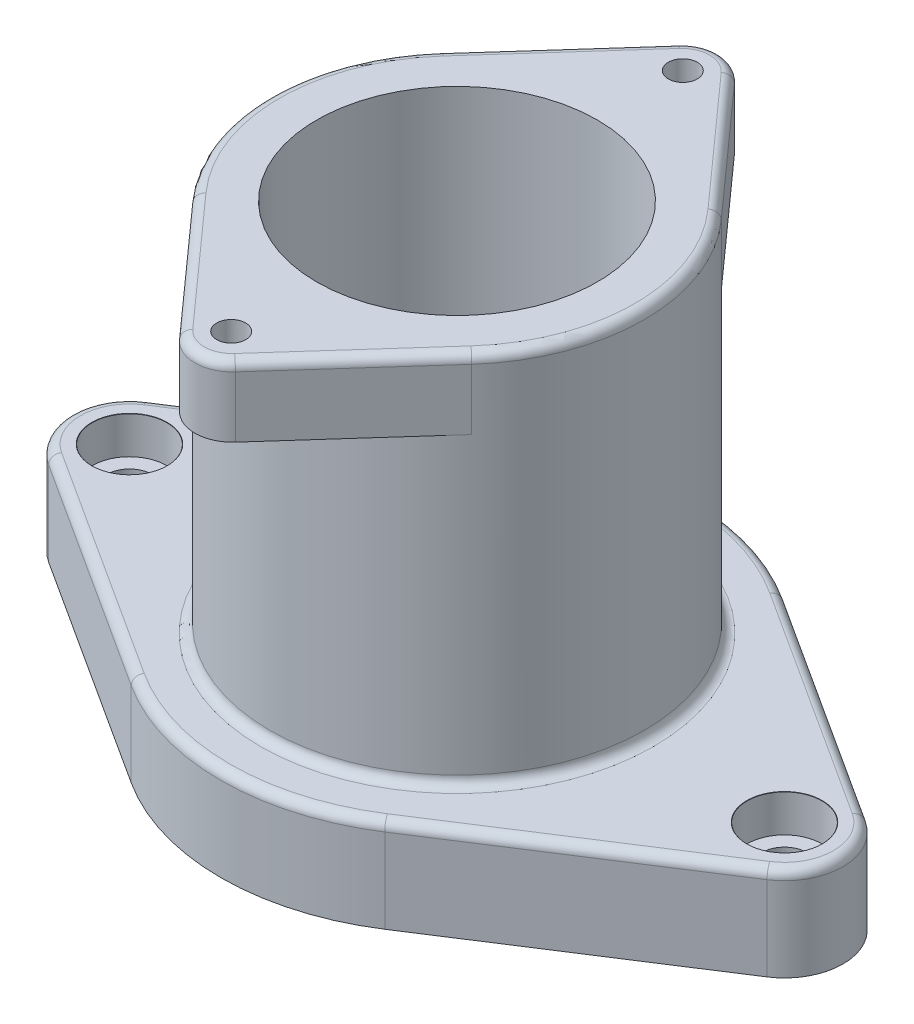
from build123d import *

# Parameters (mm, degrees)
SKETCH1_R                     = 6.25
SKETCH1_R_2                   = 20
SKETCH1_R_3                   = 15
SKETCH1_R_4                   = 1.55
BOSS_EXTRUDE1_DEPTH           = 10
SKETCH1_3_R                   = 20
SKETCH1_3_R_2                 = 15
BOSS_EXTRUDE2_DEPTH           = 40
BOSS_EXTRUDE3_START           = 40
SKETCH1_4_R                   = 1.55
BOSS_EXTRUDE3_DEPTH           = 7.5
CBORE_FOR_M4_SHCS1_AT_2_COUNT = 2
CBORE_FOR_M4_SHCS1_AT_2_PITCH = 70
FILLET1_R                     = 25
FILLET3_R                     = 4
FILLET2_R                     = 1


with BuildPart() as part:
    # Sketch1 → Boss-Extrude1 (new body)
    with BuildSketch(Plane(origin=(0, 0, 0), x_dir=(1, 0, 0), z_dir=(0, 1, 0))):
        with Locations((-35, 0)):
            Circle(SKETCH1_R)
        with BuildLine():
            Line((0, 30), (-38.386505715, 5.253006667))
            ThreePointArc((-38.386505715, 5.253006667), (-32.008609079, 5.487629758), (-28.75, 0))
            ThreePointArc((-28.75, 0), (-32.008609079, -5.487629758), (-38.386505715, -5.253006667))
            Line((-38.386505715, -5.253006667), (0, -30))
            Line((0, -30), (-14.90711985, -13.333333333))
            ThreePointArc((-14.90711985, -13.333333333), (-20, 0), (-14.90711985, 13.333333333))
            Line((-14.90711985, 13.333333333), (0, 30))
        make_face()
        Circle(SKETCH1_R_2)
        Circle(SKETCH1_R_3, mode=Mode.SUBTRACT)
        with BuildLine():
            Line((14.90711985, 13.333333333), (0, 30))
            Line((0, 30), (-14.90711985, 13.333333333))
            ThreePointArc((-14.90711985, 13.333333333), (0, 20), (14.90711985, 13.333333333))
        make_face()
        with Locations((0, 24.13)):
            Circle(SKETCH1_R_4, mode=Mode.SUBTRACT)
        with Locations((0, 24.13)):
            Circle(SKETCH1_R_4)
        with BuildLine():
            Line((38.386505715, 5.253006667), (0, 30))
            Line((0, 30), (14.90711985, 13.333333333))
            ThreePointArc((14.90711985, 13.333333333), (18.683447179, 7.136441795), (20, 0))
            ThreePointArc((20, 0), (18.683447179, -7.136441795), (14.90711985, -13.333333333))
            Line((14.90711985, -13.333333333), (0, -30))
            Line((0, -30), (38.386505715, -5.253006667))
            ThreePointArc((38.386505715, -5.253006667), (28.75, 0), (38.386505715, 5.253006667))
        make_face()
        with BuildLine():
            Line((-14.90711985, -13.333333333), (0, -30))
            Line((0, -30), (14.90711985, -13.333333333))
            ThreePointArc((14.90711985, -13.333333333), (0, -20), (-14.90711985, -13.333333333))
        make_face()
        with Locations((0, -24.13)):
            Circle(SKETCH1_R_4, mode=Mode.SUBTRACT)
        with Locations((0, -24.13)):
            Circle(SKETCH1_R_4)
        with Locations((35, 0)):
            Circle(SKETCH1_R)
    extrude(amount=-BOSS_EXTRUDE1_DEPTH)

    # Sketch1_3 → Boss-Extrude2 (add)
    with BuildSketch(Plane(origin=(0, 0, 0), x_dir=(1, 0, 0), z_dir=(0, 1, 0))):
        Circle(SKETCH1_3_R)
        Circle(SKETCH1_3_R_2, mode=Mode.SUBTRACT)
    extrude(amount=BOSS_EXTRUDE2_DEPTH)

    # Sketch1_4 → Boss-Extrude3 (add)
    with BuildSketch(Plane(origin=(0, 0, 0), x_dir=(1, 0, 0), z_dir=(0, 1, 0)).offset(BOSS_EXTRUDE3_START)):
        with BuildLine():
            Line((14.90711985, 13.333333333), (0, 30))
            Line((0, 30), (-14.90711985, 13.333333333))
            ThreePointArc((-14.90711985, 13.333333333), (0, 20), (14.90711985, 13.333333333))
        make_face()
        with Locations((0, 24.13)):
            Circle(SKETCH1_4_R, mode=Mode.SUBTRACT)
        with BuildLine():
            Line((-14.90711985, -13.333333333), (0, -30))
            Line((0, -30), (14.90711985, -13.333333333))
            ThreePointArc((14.90711985, -13.333333333), (0, -20), (-14.90711985, -13.333333333))
        make_face()
        with Locations((0, -24.13)):
            Circle(SKETCH1_4_R, mode=Mode.SUBTRACT)
    extrude(amount=-BOSS_EXTRUDE3_DEPTH)

    # Sketch3 → CBORE for M4 SHCS1 (revolve, cut)
    with BuildSketch(Plane(origin=(-35, 0, 0), x_dir=(0, 0, 1), z_dir=(1, 0, 0))):
        Polygon((0, 0), (0, 11.442065486), (2.4, 10), (2.4, 4), (4, 4), (4, 0.025), (4.025, 0), align=None)
    cbore_for_m4_shcs1 = revolve(axis=Axis((-35, 6.35, 0), (0, -1, 0)), mode=Mode.SUBTRACT)

    # CBORE for M4 SHCS1 at 2: CBORE for M4 SHCS1 ×2
    with Locations(*[(i * CBORE_FOR_M4_SHCS1_AT_2_PITCH, 0, 0) for i in range(1, CBORE_FOR_M4_SHCS1_AT_2_COUNT)]):
        add(cbore_for_m4_shcs1, mode=Mode.SUBTRACT)

    # Fillet1
    fillet1_edges = [part.edges().sort_by_distance(p)[0] for p in [
        (0, -5, -30),
        (0, -5, 30),
    ]]
    fillet(fillet1_edges, radius=FILLET1_R)

    # Fillet3
    fillet3_edges = [part.edges().sort_by_distance(p)[0] for p in [
        (0, 36.25, -30),
        (0, 36.25, 30),
    ]]
    fillet(fillet3_edges, radius=FILLET3_R)

    # Fillet2
    fillet2_edges = [part.edges().sort_by_distance(p)[0] for p in [
        (41.25, 0, 0),
        (-25.966264287, 0, 13.260081708),
        (-20, 0, 0),
        (-20, 40, 0),
        (-8.94427191, 40, -20),
        (8.94427191, 40, -20),
        (18.683447179, 40, 7.136441795),
        (8.94427191, 40, 20),
        (-8.94427191, 40, 20),
        (25.966264287, 0, -13.260081708),
        (25.966264287, 0, 13.260081708),
        (0, 0, 25.25513008),
        (0, 0, -25.25513008),
        (-41.25, 0, 0),
        (0, 40, 28),
        (0, 40, -28),
        (-25.966264287, 0, -13.260081708),
    ]]
    fillet(fillet2_edges, radius=FILLET2_R)


solid = part.part
